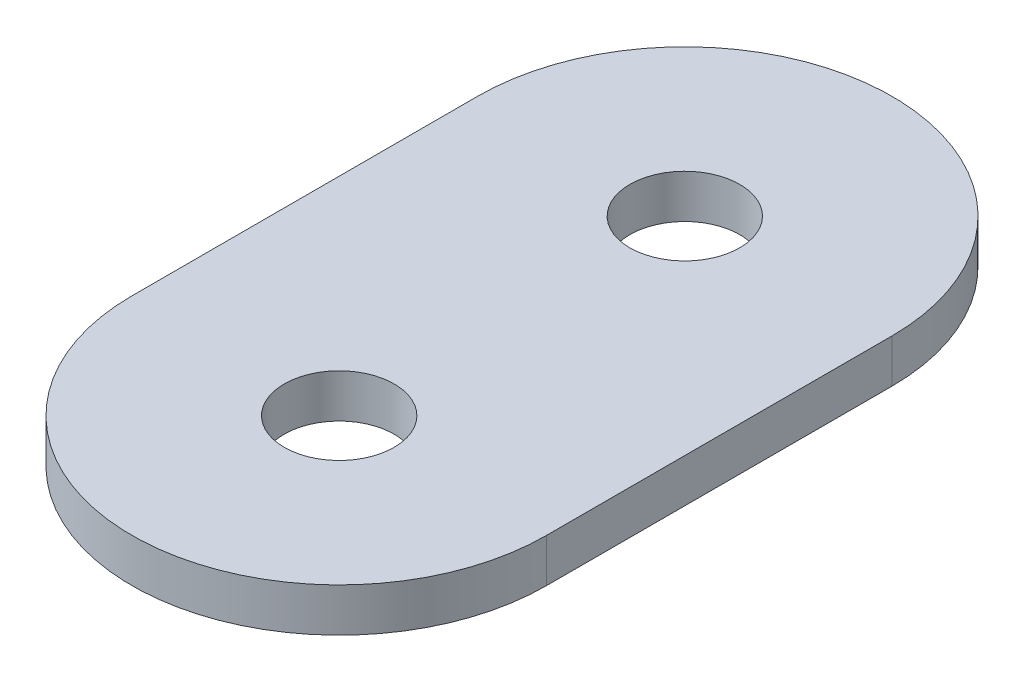
from build123d import *

# Parameters (mm, degrees)
SKETCH1_R           = 2.0193
BOSS_EXTRUDE1_DEPTH = 0.8001


with BuildPart() as part:
    # Sketch1 → Boss-Extrude1 (new body, symmetric)
    with BuildSketch(Plane(origin=(0, 0, 0), x_dir=(1, 0, 0), z_dir=(0, 1, 0))):
        with BuildLine():
            Line((-7.62, -6.35), (-7.62, 6.35))
            ThreePointArc((-7.62, 6.35), (0, 13.97), (7.62, 6.35))
            Line((7.62, 6.35), (7.62, -6.35))
            ThreePointArc((7.62, -6.35), (0, -13.97), (-7.62, -6.35))
        make_face()
        with Locations((0, 6.35)):
            Circle(SKETCH1_R, mode=Mode.SUBTRACT)
        with Locations((0, -6.35)):
            Circle(SKETCH1_R, mode=Mode.SUBTRACT)
    extrude(amount=BOSS_EXTRUDE1_DEPTH, both=True)


solid = part.part
